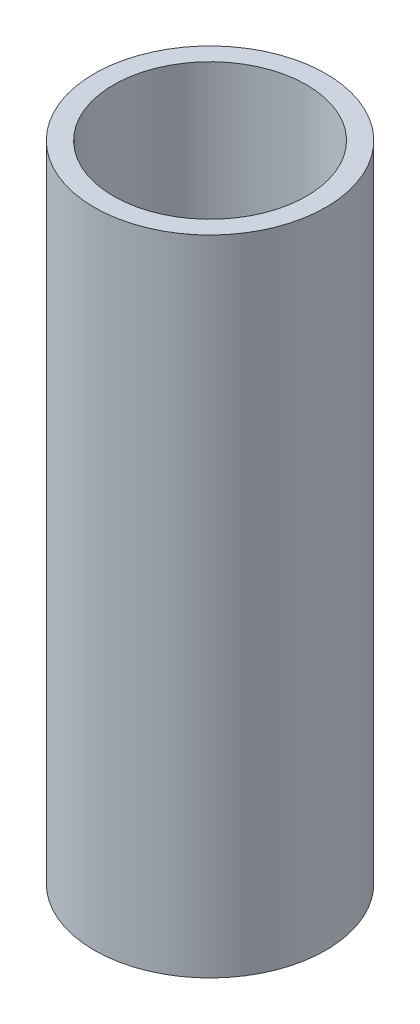
from build123d import *

# Parameters (mm, degrees)
SKETCH1_R           = 18
SKETCH1_R_2         = 15
BOSS_EXTRUDE1_DEPTH = 100


with BuildPart() as part:
    # Sketch1 → Boss-Extrude1 (new body)
    with BuildSketch(Plane(origin=(0, 0, 0), x_dir=(1, 0, 0), z_dir=(0, 1, 0))):
        with Locations(Location((0, 0, 0), (0, 0, 270))):  # turned: the seam where the file's is
            Circle(SKETCH1_R)
        with Locations(Location((0, 0, 0), (0, 0, 270))):  # turned: the seam where the file's is
            Circle(SKETCH1_R_2, mode=Mode.SUBTRACT)
    extrude(amount=BOSS_EXTRUDE1_DEPTH)


solid = part.part
